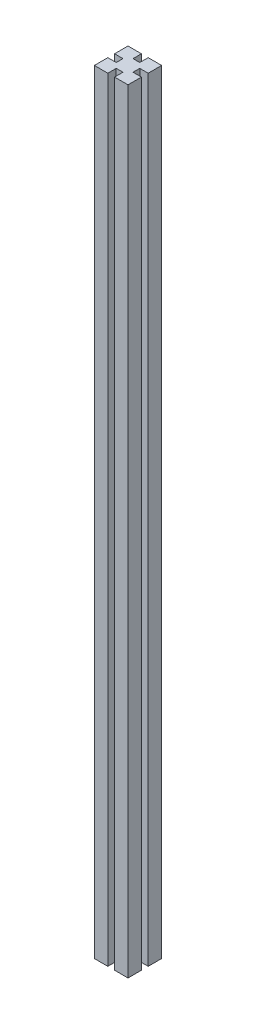
from build123d import *

# Parameters (mm, degrees)
BOSS_EXTRUDE1_DEPTH = 1150
BOSS_EXTRUDE2_DEPTH = 10


with BuildPart() as part:
    # Sketch1 → Boss-Extrude1 (new body)
    with BuildSketch(Plane(origin=(0, 0, 0), x_dir=(1, 0, 0), z_dir=(0, 1, 0))):
        Polygon((-25, 25), (-5, 25), (-5, 12.5), (5, 12.5), (5, 25), (25, 25), (25, 5), (12.5, 5), (12.5, -5), (25, -5), (25, -25), (5, -25), (5, -12.5), (-5, -12.5), (-5, -25), (-25, -25), (-25, -5), (-12.5, -5), (-12.5, 5), (-25, 5), align=None)
    extrude(amount=BOSS_EXTRUDE1_DEPTH)

    # Sketch1_2 → Boss-Extrude2 (add)
    with BuildSketch(Plane(origin=(0, 0, 0), x_dir=(1, 0, 0), z_dir=(0, 1, 0))):
        Polygon((-25, 25), (-5, 25), (-5, 12.5), (5, 12.5), (5, 25), (25, 25), (25, 5), (12.5, 5), (12.5, -5), (25, -5), (25, -25), (5, -25), (5, -12.5), (-5, -12.5), (-5, -25), (-25, -25), (-25, -5), (-12.5, -5), (-12.5, 5), (-25, 5), align=None)
    extrude(amount=BOSS_EXTRUDE2_DEPTH)


solid = part.part
